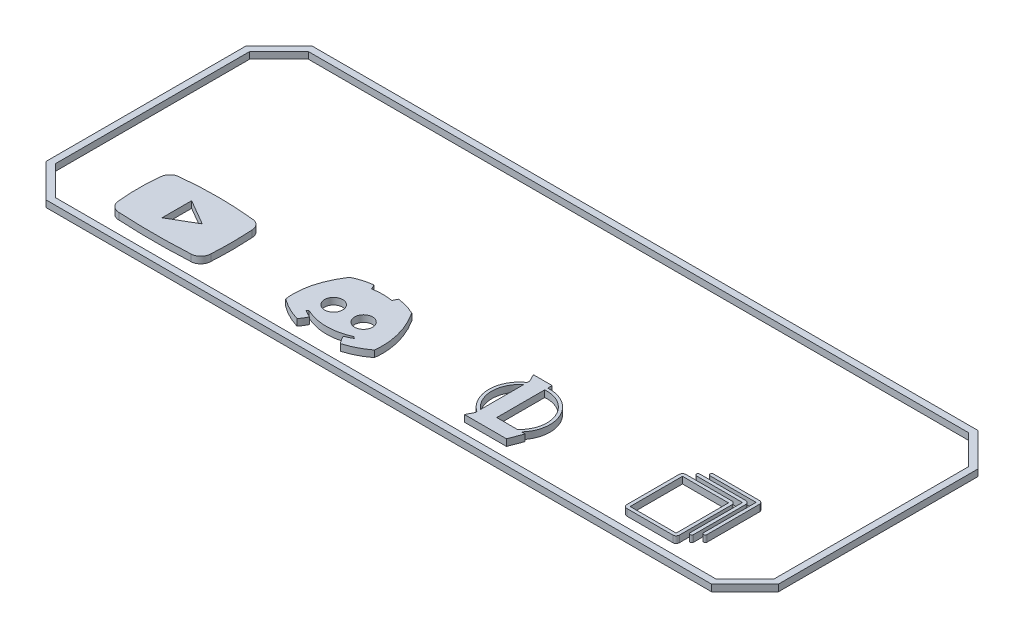
from build123d import *

# Parameters (mm, degrees)
SALIENTE_EXTRUIR1_DEPTH   = 1
CROQUIS2_R                = 1.361497815
CROQUIS2_R_2              = 1.346376897
SALIENTE_EXTRUIR2_DEPTH   = 1
SALIENTE_EXTRUIR2_2_DEPTH = 1
CROQUIS2_W                = 6.915366852
CROQUIS2_H                = 7.865481614
SALIENTE_EXTRUIR2_3_DEPTH = 1
SALIENTE_EXTRUIR2_4_DEPTH = 1
SALIENTE_EXTRUIR2_5_DEPTH = 1
SALIENTE_EXTRUIR2_6_DEPTH = 1


with BuildPart() as part:
    # Croquis1 → Saliente-Extruir1 (new body)
    with BuildSketch(Plane(origin=(0, 0, 0), x_dir=(1, 0, 0), z_dir=(0, 1, 0))):
        Polygon((-44.315779358, 24.462894216), (-39.315779358, 29.462894216), (60.684220642, 29.462894216), (65.684220642, 24.462894216), (65.684220642, -5.537105784), (60.684220642, -10.537105784), (-39.315779358, -10.537105784), (-44.315779358, -5.537105784), align=None)
        Polygon((-38.901565795, 28.462894216), (60.27000708, 28.462894216), (64.684220642, 24.048680653), (64.684220642, -5.122892222), (60.27000708, -9.537105784), (-38.901565795, -9.537105784), (-43.315779358, -5.122892222), (-43.315779358, 24.048680653), align=None, mode=Mode.SUBTRACT)
    extrude(amount=SALIENTE_EXTRUIR1_DEPTH)


with BuildPart() as body_2:
    # Croquis2 → Saliente-Extruir2 (new body)
    with BuildSketch(Plane(origin=(0, 0, 0), x_dir=(1, 0, 0), z_dir=(0, 1, 0))):
        with BuildLine():
            Line((-5.426404078, -5.396825328), (-5.154570208, -5.187722351))
            add(Edge.make_bspline(
                [(-5.154570208, -5.187722351), (-1.778047769, -6.715067504), (1.606327628, -5.187161649)],
                knots=[0, 0, 0, 1, 1, 1], degree=2))
            Line((1.606327628, -5.187161649), (1.865225464, -5.409074079))
            add(Edge.make_bspline(
                [(0.756261058, -5.951152724), (1.147976609, -5.806384801), (1.517631405, -5.625691923), (1.865225464, -5.409074079)],
                knots=[0, 0, 0, 0, 0.529469077, 0.529469077, 0.529469077, 0.529469077], degree=3))
            add(Edge.make_bspline(
                [(1.500626334, -7.123006663), (1.026812248, -6.581682279), (0.756261058, -5.951152724)],
                knots=[0, 0, 0, 0.526803373, 0.526803373, 0.526803373], degree=2))
            add(Edge.make_bspline(
                [(4.873813374, -5.414509331), (3.301106847, -6.600422577), (1.500626334, -7.123006663)],
                knots=[0, 0, 0, 0.673867536, 0.673867536, 0.673867536], degree=2))
            add(Edge.make_bspline(
                [(2.891518393, 2.197065323), (5.335713187, -1.605769838), (4.873813374, -5.414509331)],
                knots=[0, 0, 0, 0.738778588, 0.738778588, 0.738778588], degree=2))
            add(Edge.make_bspline(
                [(0.109734275, 3.029410177), (1.596446356, 2.818732188), (2.891518393, 2.197065323)],
                knots=[0, 0, 0, 0.538264783, 0.538264783, 0.538264783], degree=2))
            add(Edge.make_bspline(
                [(0.109734275, 3.029410177), (-0.111898226, 2.70326467), (-0.230911201, 2.343767826)],
                knots=[0, 0, 0, 0.481523114, 0.481523114, 0.481523114], degree=2))
            add(Edge.make_bspline(
                [(-3.303499979, 2.328290465), (-1.769398985, 2.615501041), (-0.230911201, 2.343767826)],
                knots=[0, 0, 0, 1, 1, 1], degree=2))
            add(Edge.make_bspline(
                [(-3.624865664, 3.029410177), (-3.482156193, 2.806092888), (-3.375045086, 2.572423128), (-3.303499979, 2.328290465)],
                knots=[0, 0, 0, 0, 0.489643316, 0.489643316, 0.489643316, 0.489643316], degree=3))
            add(Edge.make_bspline(
                [(-3.624865664, 3.029410177), (-5.132917301, 2.840619601), (-6.4395055, 2.197065323)],
                knots=[0, 0, 0, 0.656124826, 0.656124826, 0.656124826], degree=2))
            add(Edge.make_bspline(
                [(-6.4395055, 2.197065323), (-8.921718156, -1.590554285), (-8.432752387, -5.414509331)],
                knots=[0, 0, 0, 0.78193849, 0.78193849, 0.78193849], degree=2))
            add(Edge.make_bspline(
                [(-8.432752387, -5.414509331), (-6.836935569, -6.602143075), (-5.015757723, -7.123006663)],
                knots=[0, 0, 0, 0.671017773, 0.671017773, 0.671017773], degree=2))
            add(Edge.make_bspline(
                [(-5.015757723, -7.123006663), (-4.585994773, -6.585318237), (-4.315243519, -5.97687157)],
                knots=[0, 0, 0, 0.510782069, 0.510782069, 0.510782069], degree=2))
            add(Edge.make_bspline(
                [(-4.315243519, -5.97687157), (-4.695614995, -5.800597715), (-5.066001846, -5.607248965), (-5.426404078, -5.396825328)],
                knots=[0, 0, 0, 0, 0.479761456, 0.479761456, 0.479761456, 0.479761456], degree=3))
        make_face()
        with Locations((-4.065779358, -2.580256668)):
            Circle(CROQUIS2_R, mode=Mode.SUBTRACT)
        with Locations((0.434220642, -2.580256668)):
            Circle(CROQUIS2_R_2, mode=Mode.SUBTRACT)
    extrude(amount=SALIENTE_EXTRUIR2_DEPTH)


with BuildPart() as body_3:
    # Croquis2 → Saliente-Extruir2 2 (new body)
    with BuildSketch(Plane(origin=(0, 0, 0), x_dir=(1, 0, 0), z_dir=(0, 1, 0))):
        with BuildLine():
            Line((20.045620158, 3.322115288), (22.856440669, 3.322115288))
            Line((22.856440669, 3.322115288), (22.856440669, 2.651881324))
            ThreePointArc((22.856440669, 2.651881324), (27.310139453, 0.087946094), (26.597494702, -5.001389244))
            Line((26.597494702, -5.001389244), (27.123697346, -5.001389244))
            Line((27.123697346, -5.001389244), (26.350477055, -7.035124087))
            Line((26.350477055, -7.035124087), (20.045620158, -7.035124087))
            Line((20.045620158, -7.035124087), (20.59503046, -5.951152724))
            Line((20.59503046, -5.951152724), (20.59503046, -5.721878986))
            ThreePointArc((20.59503046, -5.721878986), (18.591751, -1.928876005), (20.59503046, 1.864126976))
            Line((20.59503046, 1.864126976), (20.59503046, 2.197065323))
            Line((20.59503046, 2.197065323), (20.045620158, 3.322115288))
        make_face()
        with BuildLine():
            Line((22.856440669, -5.001389244), (25.964881426, -5.001389244))
            ThreePointArc((25.964881426, -5.001389244), (26.989049751, -0.287021123), (22.856440669, 2.202101155))
            Line((22.856440669, 2.202101155), (22.856440669, -5.001389244))
        make_face(mode=Mode.SUBTRACT)
        with BuildLine():
            Line((20.59503046, -5.164383106), (20.59503046, 1.306631097))
            ThreePointArc((20.59503046, 1.306631097), (19.040259735, -1.928876005), (20.59503046, -5.164383106))
        make_face(mode=Mode.SUBTRACT)
    extrude(amount=SALIENTE_EXTRUIR2_2_DEPTH)


with BuildPart() as body_4:
    # Croquis2 → Saliente-Extruir2 3 (new body)
    with BuildSketch(Plane(origin=(0, 0, 0), x_dir=(1, 0, 0), z_dir=(0, 1, 0))):
        with BuildLine():
            Line((44.448553025, 1.806631097), (51.363919877, 1.806631097))
            ThreePointArc((51.363919877, 1.806631097), (51.717473267, 1.660184488), (51.863919877, 1.306631097))
            Line((51.863919877, 1.306631097), (51.863919877, -6.558850517))
            ThreePointArc((51.863919877, -6.558850517), (51.717473267, -6.912403908), (51.363919877, -7.058850517))
            Line((51.363919877, -7.058850517), (44.448553025, -7.058850517))
            ThreePointArc((44.448553025, -7.058850517), (44.094999635, -6.912403908), (43.948553025, -6.558850517))
            Line((43.948553025, -6.558850517), (43.948553025, 1.306631097))
            ThreePointArc((43.948553025, 1.306631097), (44.094999635, 1.660184488), (44.448553025, 1.806631097))
        make_face()
        with Locations((47.906236451, -2.62610971)):
            Rectangle(CROQUIS2_W, CROQUIS2_H, mode=Mode.SUBTRACT)
    extrude(amount=SALIENTE_EXTRUIR2_3_DEPTH)


with BuildPart() as body_5:
    # Croquis2 → Saliente-Extruir2 4 (new body)
    with BuildSketch(Plane(origin=(0, 0, 0), x_dir=(1, 0, 0), z_dir=(0, 1, 0))):
        with BuildLine():
            Line((45.448311848, 2.90454651), (52.3636787, 2.90454651))
            ThreePointArc((52.3636787, 2.90454651), (52.71723209, 2.758099901), (52.8636787, 2.40454651))
            Line((52.8636787, 2.40454651), (52.8636787, -5.460935104))
            ThreePointArc((52.8636787, -5.460935104), (52.6136787, -5.710935104), (52.3636787, -5.460935104))
            Line((52.3636787, -5.460935104), (52.3636787, 2.40454651))
            Line((52.3636787, 2.40454651), (45.448311848, 2.40454651))
            ThreePointArc((45.448311848, 2.40454651), (45.198311848, 2.65454651), (45.448311848, 2.90454651))
        make_face()
    extrude(amount=SALIENTE_EXTRUIR2_4_DEPTH)


with BuildPart() as body_6:
    # Croquis2 → Saliente-Extruir2 5 (new body)
    with BuildSketch(Plane(origin=(0, 0, 0), x_dir=(1, 0, 0), z_dir=(0, 1, 0))):
        with BuildLine():
            Line((46.455317987, 3.939141858), (53.370684838, 3.939141858))
            ThreePointArc((53.370684838, 3.939141858), (53.724238229, 3.792695248), (53.870684838, 3.439141858))
            Line((53.870684838, 3.439141858), (53.870684838, -4.426339756))
            ThreePointArc((53.870684838, -4.426339756), (53.620684838, -4.676339756), (53.370684838, -4.426339756))
            Line((53.370684838, -4.426339756), (53.370684838, 3.439141858))
            Line((53.370684838, 3.439141858), (46.455317987, 3.439141858))
            ThreePointArc((46.455317987, 3.439141858), (46.205317987, 3.689141858), (46.455317987, 3.939141858))
        make_face()
    extrude(amount=SALIENTE_EXTRUIR2_5_DEPTH)


with BuildPart() as body_7:
    # Croquis2 → Saliente-Extruir2 6 (new body)
    with BuildSketch(Plane(origin=(0, 0, 0), x_dir=(1, 0, 0), z_dir=(0, 1, 0))):
        with BuildLine():
            ThreePointArc((-32.215779358, 2.475392476), (-33.27643953, 2.036052648), (-33.715779358, 0.975392476))
            add(Edge.make_bspline(
                [(-33.715779358, 0.975392476), (-34.060193738, -2.145099996), (-33.715779358, -5.187722351)],
                knots=[0, 0, 0, 0.500652544, 0.500652544, 0.500652544], degree=2))
            ThreePointArc((-33.715779358, -5.187722351), (-33.27643953, -6.248382523), (-32.215779358, -6.687722351))
            add(Edge.make_bspline(
                [(-32.215779358, -6.687722351), (-26.800341588, -6.988342953), (-21.415779358, -6.687722351)],
                knots=[0, 0, 0, 0.543466747, 0.543466747, 0.543466747], degree=2))
            ThreePointArc((-21.415779358, -6.687722351), (-20.355119186, -6.248382523), (-19.915779358, -5.187722351))
            add(Edge.make_bspline(
                [(-19.915779358, 0.975392476), (-19.722500126, -2.118211874), (-19.915779358, -5.187722351)],
                knots=[0, 0, 0, 0.505100069, 0.505100069, 0.505100069], degree=2))
            ThreePointArc((-19.915779358, 0.975392476), (-20.355119186, 2.036052648), (-21.415779358, 2.475392476))
            add(Edge.make_bspline(
                [(-32.215779358, 2.475392476), (-26.758622525, 3.049836136), (-21.415779358, 2.475392476)],
                knots=[0, 0, 0, 0.539860314, 0.539860314, 0.539860314], degree=2))
        make_face()
        Polygon((-28.268379534, 0.293537194), (-28.268379534, -4.151289204), (-24.455058525, -1.928876005), align=None, mode=Mode.SUBTRACT)
    extrude(amount=SALIENTE_EXTRUIR2_6_DEPTH)


solid = Compound([part.part, body_2.part, body_3.part, body_4.part, body_5.part, body_6.part, body_7.part])
